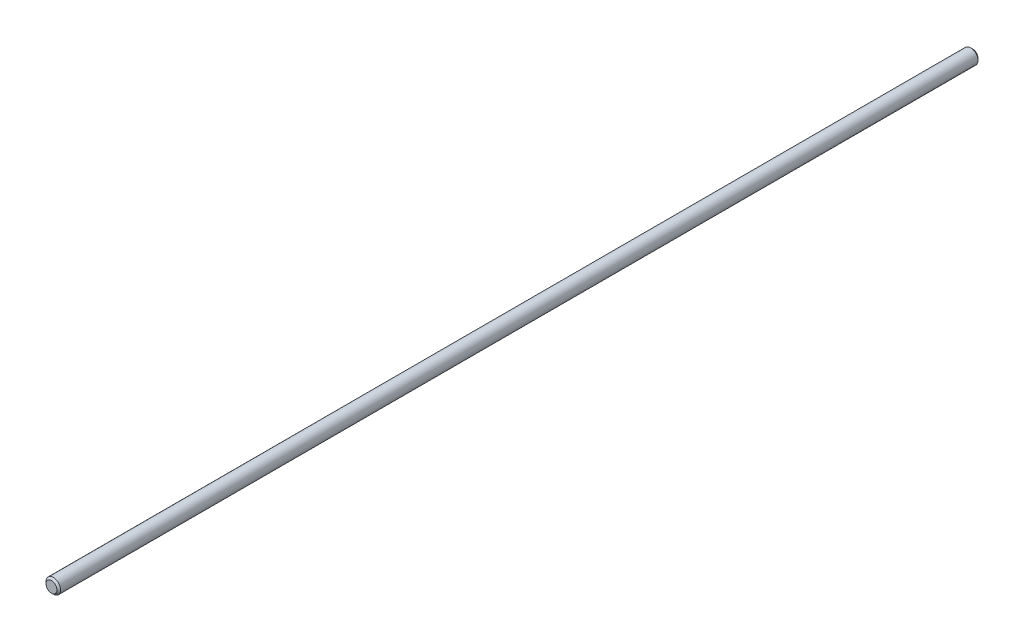
from build123d import *

# Parameters (mm, degrees)
SKETCH_1_R      = 4
EXTRUDE_1_DEPTH = 505
CHAMFER_1_SIZE  = 1


with BuildPart() as part:
    # 草图1 → 凸台-拉伸1 (new body)
    with BuildSketch(Plane.XY):
        Circle(SKETCH_1_R)
    extrude(amount=EXTRUDE_1_DEPTH)

    # 倒角1
    chamfer_1_edges = [part.edges().sort_by_distance(p)[0] for p in [
        (-4, 0, 0),
        (-4, 0, 505),
    ]]
    chamfer(chamfer_1_edges, length=CHAMFER_1_SIZE)


solid = part.part
